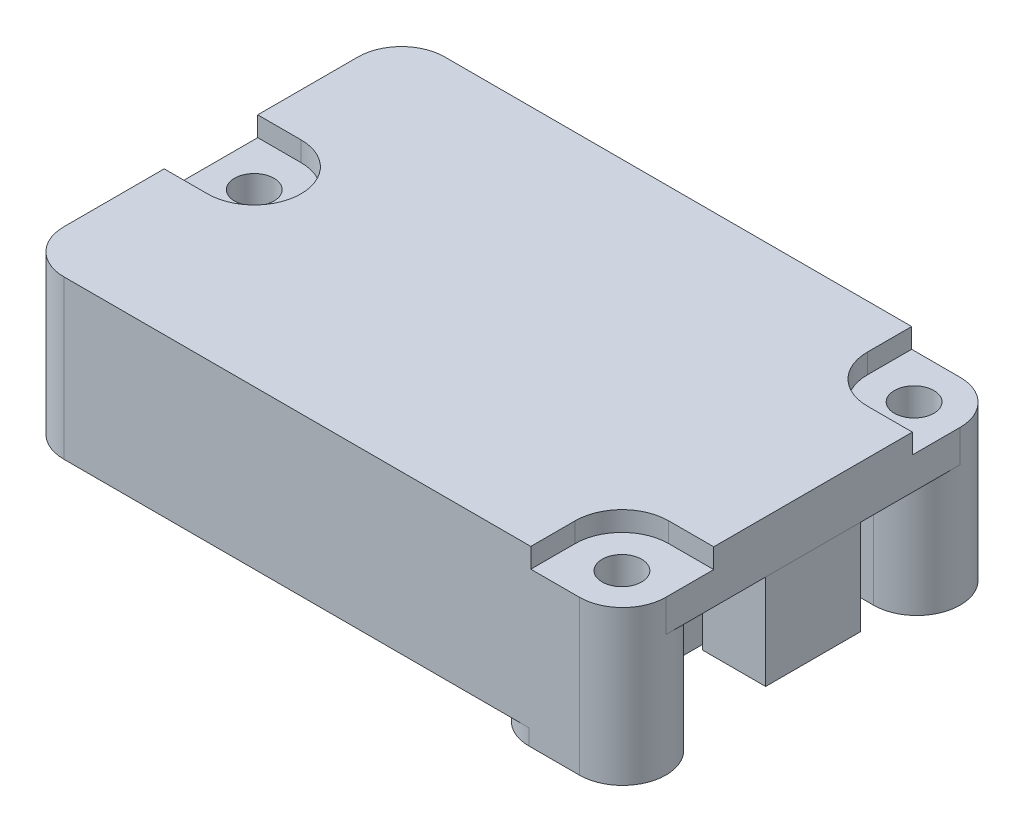
from build123d import *

# Parameters (mm, degrees)
SKIZZE1_R                       = 1.25
AUFSATZ_LINEAR_AUSTRAGEN1_DEPTH = 11
SCHNITT_LINEAR_AUSTRAGEN1_DEPTH = 1.25
SKIZZE3_OUTSIDE_W               = 49.38
SKIZZE3_OUTSIDE_H               = 35.38
SKIZZE3_OUTSIDE_R               = 2.75
SCHNITT_LINEAR_AUSTRAGEN2_DEPTH = 1
SCHNITT_LINEAR_AUSTRAGEN3_DEPTH = 6.7
SKIZZE5_W                       = 4
SKIZZE5_H                       = 6
AUFSATZ_LINEAR_AUSTRAGEN2_DEPTH = 6


with BuildPart() as part:
    # Skizze1 → Aufsatz-Linear austragen1 (new body)
    with BuildSketch(Plane(origin=(0, 0, 0), x_dir=(1, 0, 0), z_dir=(0, 1, 0))):
        with BuildLine():
            Line((-19.05, -9.31), (-19.05, 9.31))
            ThreePointArc((-19.05, 9.31), (-18.24747258, 11.24747258), (-16.31, 12.05))
            Line((-16.31, 12.05), (16.31, 12.05))
            ThreePointArc((16.31, 12.05), (18.24747258, 11.24747258), (19.05, 9.31))
            Line((19.05, 9.31), (19.05, -9.31))
            ThreePointArc((19.05, -9.31), (18.24747258, -11.24747258), (16.31, -12.05))
            Line((16.31, -12.05), (-16.31, -12.05))
            ThreePointArc((-16.31, -12.05), (-18.24747258, -11.24747258), (-19.05, -9.31))
        make_face()
        with Locations((16.2, 9.245)):
            Circle(SKIZZE1_R, mode=Mode.SUBTRACT)
        with Locations((16.2, -9.245)):
            Circle(SKIZZE1_R, mode=Mode.SUBTRACT)
        with Locations((-16.31, 0)):
            Circle(SKIZZE1_R, mode=Mode.SUBTRACT)
    extrude(amount=AUFSATZ_LINEAR_AUSTRAGEN1_DEPTH)

    # Skizze2 → Schnitt-Linear austragen1 (cut)
    with BuildSketch(Plane(origin=(0, 11, 0), x_dir=(1, 0, 0), z_dir=(0, 1, 0))):
        with BuildLine():
            Line((-19.05, -2.96), (-19.05, 2.96))
            Line((-19.05, 2.96), (-16.31, 2.96))
            ThreePointArc((-16.31, 2.96), (-13.35, 0), (-16.31, -2.96))
            Line((-16.31, -2.96), (-19.05, -2.96))
        make_face()
        with BuildLine():
            Line((13.24, 12.05), (13.24, 9.245))
            ThreePointArc((13.24, 9.245), (14.106963928, 7.151963928), (16.2, 6.285))
            Line((16.2, 6.285), (19.05, 6.285))
            Line((19.05, 6.285), (19.05, 12.05))
            Line((19.05, 12.05), (13.24, 12.05))
        make_face()
        with BuildLine():
            Line((19.05, -12.05), (13.24, -12.05))
            Line((13.24, -12.05), (13.24, -9.245))
            ThreePointArc((13.24, -9.245), (14.106963928, -7.151963928), (16.2, -6.285))
            Line((16.2, -6.285), (19.05, -6.285))
            Line((19.05, -6.285), (19.05, -12.05))
        make_face()
    extrude(amount=-SCHNITT_LINEAR_AUSTRAGEN1_DEPTH, mode=Mode.SUBTRACT)

    # Skizze3 outside → Schnitt-Linear austragen2 (cut)
    with BuildSketch(Plane.XZ):
        Rectangle(SKIZZE3_OUTSIDE_W, SKIZZE3_OUTSIDE_H)
        with Locations((-16.31, 0)):
            Circle(SKIZZE3_OUTSIDE_R, mode=Mode.SUBTRACT)
        with BuildLine():
            Line((13.14, 12.05), (16.31, 12.05))
            ThreePointArc((16.31, 12.05), (19.05, 9.31), (16.31, 6.57))
            Line((16.31, 6.57), (13.14, 6.57))
            ThreePointArc((13.14, 6.57), (10.4, 9.31), (13.14, 12.05))
        make_face(mode=Mode.SUBTRACT)
        with BuildLine():
            Line((13.14, -12.05), (16.31, -12.05))
            ThreePointArc((16.31, -12.05), (19.05, -9.31), (16.31, -6.57))
            Line((16.31, -6.57), (13.14, -6.57))
            ThreePointArc((13.14, -6.57), (10.4, -9.31), (13.14, -12.05))
        make_face(mode=Mode.SUBTRACT)
    extrude(amount=-SCHNITT_LINEAR_AUSTRAGEN2_DEPTH, mode=Mode.SUBTRACT)

    # Skizze4 → Schnitt-Linear austragen3 (cut)
    with BuildSketch(Plane.XZ.offset(-1)):
        with BuildLine():
            Line((16.31, 6.57), (15.05, 6.57))
            ThreePointArc((15.05, 6.57), (14.342893219, 6.277106781), (14.05, 5.57))
            Line((14.05, 5.57), (14.05, -5.57))
            ThreePointArc((14.05, -5.57), (14.342893219, -6.277106781), (15.05, -6.57))
            Line((15.05, -6.57), (16.31, -6.57))
            ThreePointArc((16.31, -6.57), (18.24747258, -7.37252742), (19.05, -9.31))
            Line((19.05, -9.31), (19.05, 9.31))
            ThreePointArc((19.05, 9.31), (18.24747258, 7.37252742), (16.31, 6.57))
        make_face()
    extrude(amount=-SCHNITT_LINEAR_AUSTRAGEN3_DEPTH, mode=Mode.SUBTRACT)

    # Skizze5 → Aufsatz-Linear austragen2 (add)
    with BuildSketch(Plane.XZ.offset(-7.7)):
        with Locations((17.049, 0)):
            Rectangle(SKIZZE5_W, SKIZZE5_H)
    extrude(amount=AUFSATZ_LINEAR_AUSTRAGEN2_DEPTH)


solid = part.part
